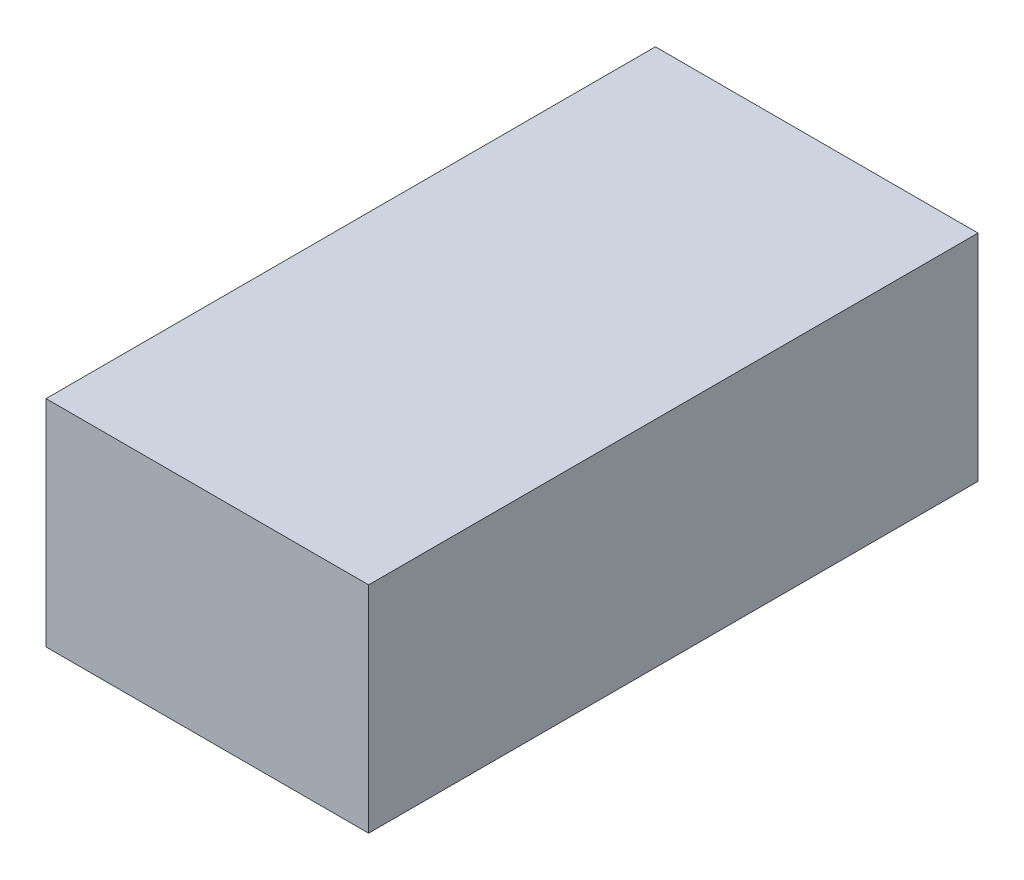
from build123d import *

# Parameters (mm, degrees)
SKETCH1_W           = 45
SKETCH1_H           = 85
BOSS_EXTRUDE1_DEPTH = 30


with BuildPart() as part:
    # Sketch1 → Boss-Extrude1 (new body)
    with BuildSketch(Plane(origin=(0, 0, 0), x_dir=(1, 0, 0), z_dir=(0, 1, 0))):
        Rectangle(SKETCH1_W, SKETCH1_H)
    extrude(amount=BOSS_EXTRUDE1_DEPTH)


solid = part.part
